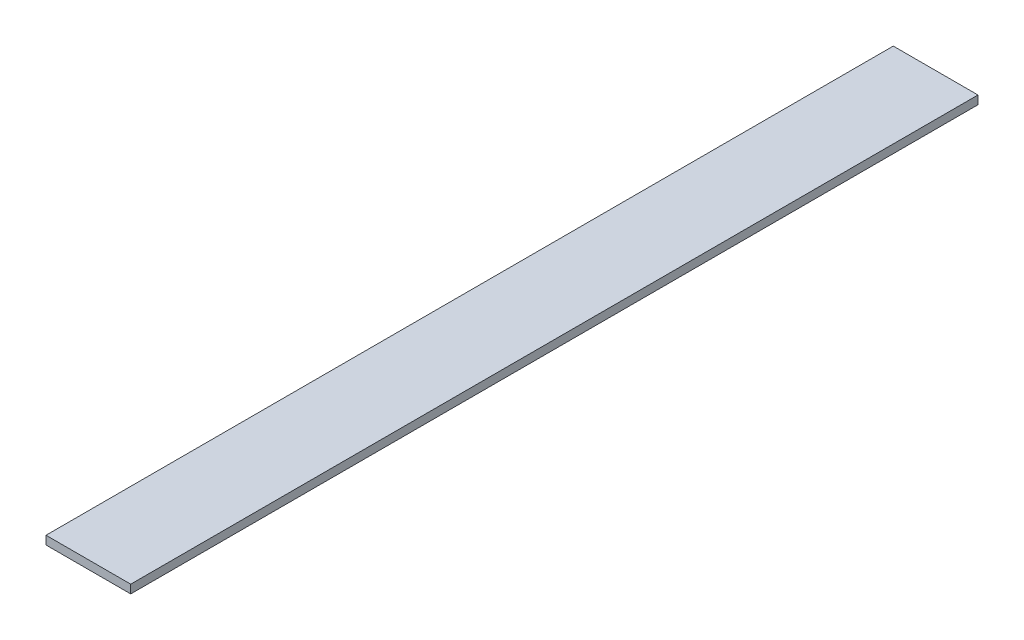
from build123d import *

# Parameters (mm, degrees)
SKETCH1_W           = 63.5
SKETCH1_H           = 6.35
BOSS_EXTRUDE1_DEPTH = 635


with BuildPart() as part:
    # Sketch1 → Boss-Extrude1 (new body)
    with BuildSketch(Plane.XY):
        with Locations((31.75, 3.175)):
            Rectangle(SKETCH1_W, SKETCH1_H)
    extrude(amount=BOSS_EXTRUDE1_DEPTH)


solid = part.part
